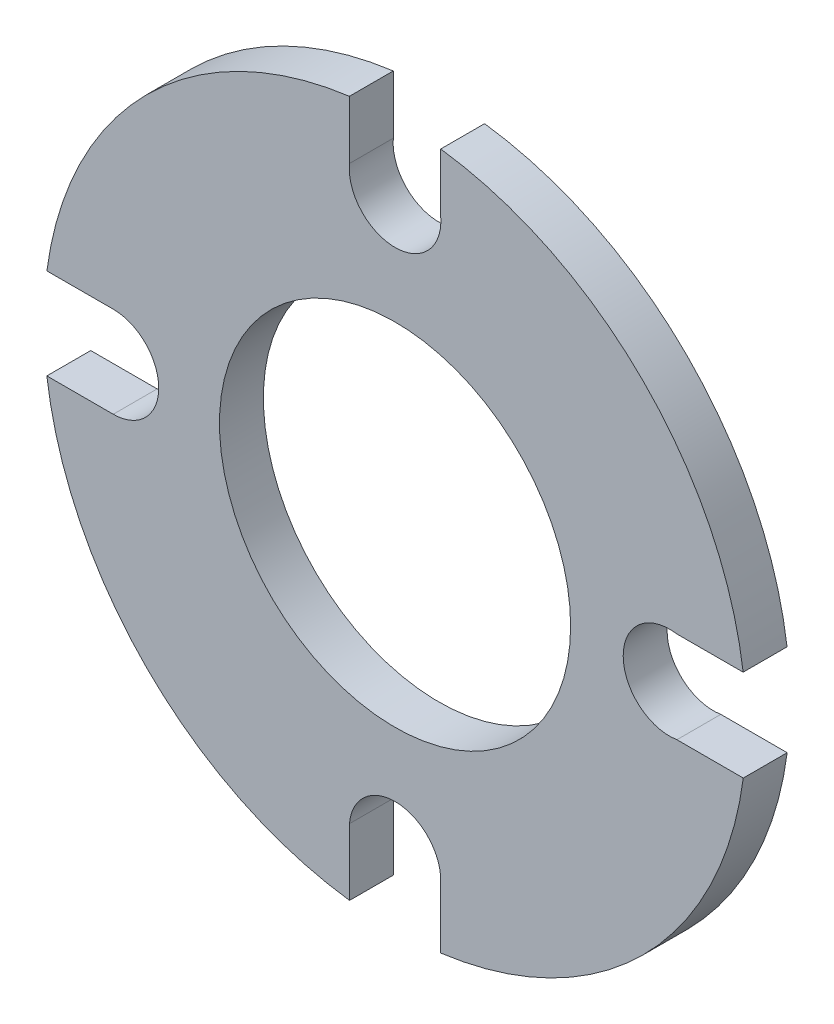
from build123d import *

# Parameters (mm, degrees)
SKETCH1_R           = 50
BOSS_EXTRUDE1_DEPTH = 12.5


with BuildPart() as part:
    # Sketch1 → Boss-Extrude1 (new body)
    with BuildSketch(Plane.XY):
        with BuildLine():
            ThreePointArc((80.269796006, -12.90154445), (64.968632792, 0.106555165), (80.22704459, 13.164775589))
            Line((80.22704459, 13.164775589), (99.127347992, 13.182142467))
            ThreePointArc((99.127347992, 13.182142467), (70.645692195, 70.775604372), (13, 99.151399385))
            Line((13, 99.151399385), (12.998692028, 82.58389221))
            ThreePointArc((12.998692028, 82.58389221), (1.164991508, 68.412255439), (-13, 80.253909562))
            ThreePointArc((-13, 80.253909562), (-13.051446481, 81.411603502), (-13, 82.569297441))
            Line((-13, 82.569297441), (-13, 99.151399385))
            ThreePointArc((-13, 99.151399385), (-70.710695757, 70.71066048), (-99.151405871, 12.999950534))
            Line((-99.151405871, 12.999950534), (-80.251102468, 13.017317412))
            ThreePointArc((-80.251102468, 13.017317412), (-67.29756358, 0.062140866), (-80.252740126, -12.891398023))
            Line((-80.252740126, -12.891398023), (-99.165733386, -12.890202557))
            ThreePointArc((-99.165733386, -12.890202557), (-70.737321503, -70.684024692), (-12.964943151, -99.155989477))
            Line((-12.964943151, -99.155989477), (-12.984340134, -80.237755153))
            ThreePointArc((-12.984340134, -80.237755153), (0.009254017, -68.272284652), (12.985836125, -80.256202627))
            Line((12.985836125, -80.256202627), (12.984344225, -99.153450797))
            ThreePointArc((12.984344225, -99.153450797), (70.739768795, -70.681575469), (99.164103047, -12.902738735))
            Line((99.164103047, -12.902738735), (80.269796006, -12.90154445))
        make_face()
        Circle(SKETCH1_R, mode=Mode.SUBTRACT)
    extrude(amount=BOSS_EXTRUDE1_DEPTH)


solid = part.part
